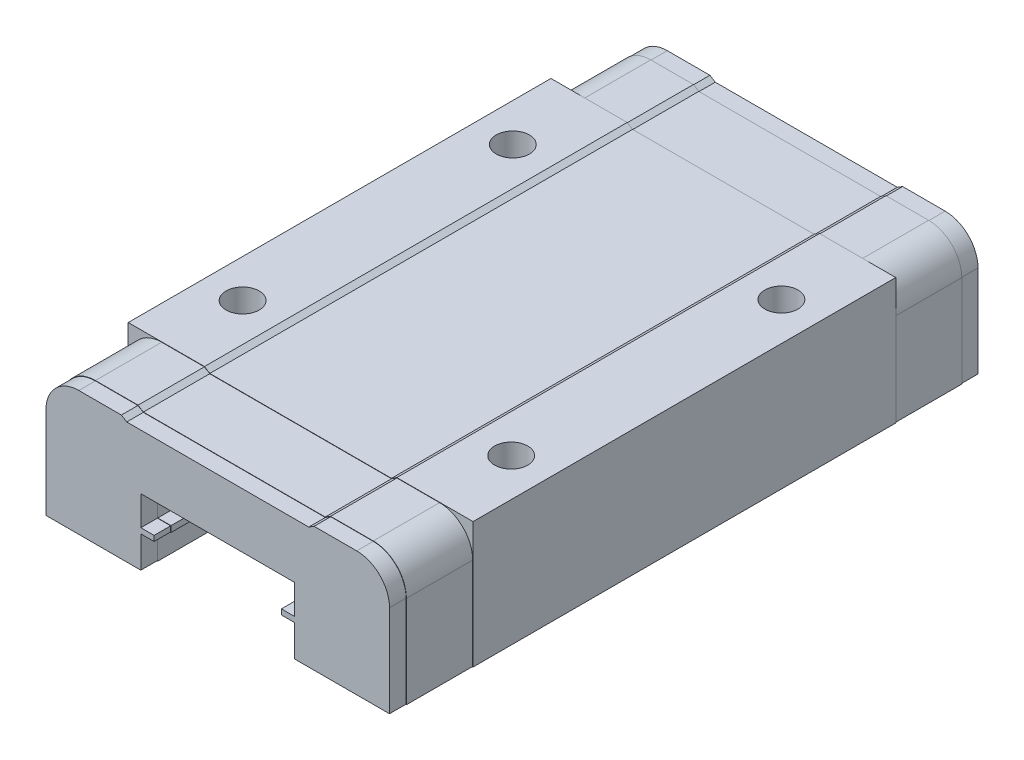
from build123d import *

# Parameters (mm, degrees)
BOSS_EXTRUDE1_DEPTH = 16.1925
SKETCH2_R           = 1.27
CUT_EXTRUDE1_DEPTH  = 5.08
BOSS_EXTRUDE2_DEPTH = 5.08
BOSS_EXTRUDE3_DEPTH = 1.27


with BuildPart() as part:
    # Sketch1 → Boss-Extrude1 (new body, symmetric)
    with BuildSketch(Plane.XY):
        Polygon((13.208, 0.254), (13.208, -9.398), (5.842, -9.398), (5.842, -6.985), (4.826, -6.985), (4.826, -6.477), (5.842, -6.477), (5.842, -4.318), (-5.842, -4.318), (-5.842, -6.477), (-4.826, -6.477), (-4.826, -6.985), (-5.842, -6.985), (-5.842, -9.398), (-13.208, -9.398), (-13.208, 0.254), (-7.367499011, 0.254), (-6.958302098, 0), (6.958302098, 0), (7.367499011, 0.254), align=None)
    extrude(amount=BOSS_EXTRUDE1_DEPTH, both=True)

    # Sketch2 → Cut-Extrude1 (cut)
    with BuildSketch(Plane(origin=(0, 0.254, 0), x_dir=(1, 0, 0), z_dir=(0, 1, 0))):
        with Locations((-10.287749506, 10.3505)):
            Circle(SKETCH2_R)
        with Locations((10.287749506, 10.3505)):
            Circle(SKETCH2_R)
        with Locations((10.287749506, -10.3505)):
            Circle(SKETCH2_R)
        with Locations((-10.287749506, -10.3505)):
            Circle(SKETCH2_R)
    extrude(amount=-CUT_EXTRUDE1_DEPTH, mode=Mode.SUBTRACT)

    # Sketch3 → Boss-Extrude2 (add)
    with BuildSketch(Plane.XY.offset(16.1925)):
        with BuildLine():
            Line((5.8674, -4.2926), (5.8674, -6.5024))
            Line((5.8674, -6.5024), (4.8514, -6.5024))
            Line((4.8514, -6.5024), (4.8514, -6.9596))
            Line((4.8514, -6.9596), (5.8674, -6.9596))
            Line((5.8674, -6.9596), (5.8674, -9.3726))
            Line((5.8674, -9.3726), (13.1826, -9.3726))
            Line((13.1826, -9.3726), (13.1826, -2.3114))
            ThreePointArc((13.1826, -2.3114), (12.438651224, -0.515348776), (10.6426, 0.2286))
            Line((10.6426, 0.2286), (7.37474135, 0.2286))
            Line((7.37474135, 0.2286), (6.965544437, -0.0254))
            Line((6.965544437, -0.0254), (-6.965544437, -0.0254))
            Line((-6.965544437, -0.0254), (-7.37474135, 0.2286))
            Line((-7.37474135, 0.2286), (-10.6426, 0.2286))
            ThreePointArc((-10.6426, 0.2286), (-12.438651224, -0.515348776), (-13.1826, -2.3114))
            Line((-13.1826, -2.3114), (-13.1826, -9.3726))
            Line((-13.1826, -9.3726), (-5.8674, -9.3726))
            Line((-5.8674, -9.3726), (-5.8674, -6.9596))
            Line((-5.8674, -6.9596), (-4.8514, -6.9596))
            Line((-4.8514, -6.9596), (-4.8514, -6.5024))
            Line((-4.8514, -6.5024), (-5.8674, -6.5024))
            Line((-5.8674, -6.5024), (-5.8674, -4.2926))
            Line((-5.8674, -4.2926), (5.8674, -4.2926))
        make_face()
    boss_extrude2 = extrude(amount=BOSS_EXTRUDE2_DEPTH)

    # Sketch5 → Boss-Extrude3 (add)
    with BuildSketch(Plane.XY.offset(21.2725)):
        with BuildLine():
            Line((13.1572, -9.3472), (13.1572, -2.3114))
            ThreePointArc((13.1572, -2.3114), (12.420690712, -0.533309288), (10.6426, 0.2032))
            Line((10.6426, 0.2032), (7.381983689, 0.2032))
            Line((7.381983689, 0.2032), (6.972786776, -0.0508))
            Line((6.972786776, -0.0508), (-6.972786776, -0.0508))
            Line((-6.972786776, -0.0508), (-7.381983689, 0.2032))
            Line((-7.381983689, 0.2032), (-10.6426, 0.2032))
            ThreePointArc((-10.6426, 0.2032), (-12.420690712, -0.533309288), (-13.1572, -2.3114))
            Line((-13.1572, -2.3114), (-13.1572, -9.3472))
            Line((-13.1572, -9.3472), (-5.8928, -9.3472))
            Line((-5.8928, -9.3472), (-5.8928, -6.9342))
            Line((-5.8928, -6.9342), (-4.8768, -6.9342))
            Line((-4.8768, -6.9342), (-4.8768, -6.5278))
            Line((-4.8768, -6.5278), (-5.8928, -6.5278))
            Line((-5.8928, -6.5278), (-5.8928, -4.2672))
            Line((-5.8928, -4.2672), (5.8928, -4.2672))
            Line((5.8928, -4.2672), (5.8928, -6.5278))
            Line((5.8928, -6.5278), (4.8768, -6.5278))
            Line((4.8768, -6.5278), (4.8768, -6.9342))
            Line((4.8768, -6.9342), (5.8928, -6.9342))
            Line((5.8928, -6.9342), (5.8928, -9.3472))
            Line((5.8928, -9.3472), (13.1572, -9.3472))
        make_face()
    boss_extrude3 = extrude(amount=BOSS_EXTRUDE3_DEPTH)

    # Mirror2: Boss-Extrude2, Boss-Extrude3 across plane
    add(boss_extrude2.mirror(Plane.XY))
    add(boss_extrude3.mirror(Plane.XY))


solid = part.part
